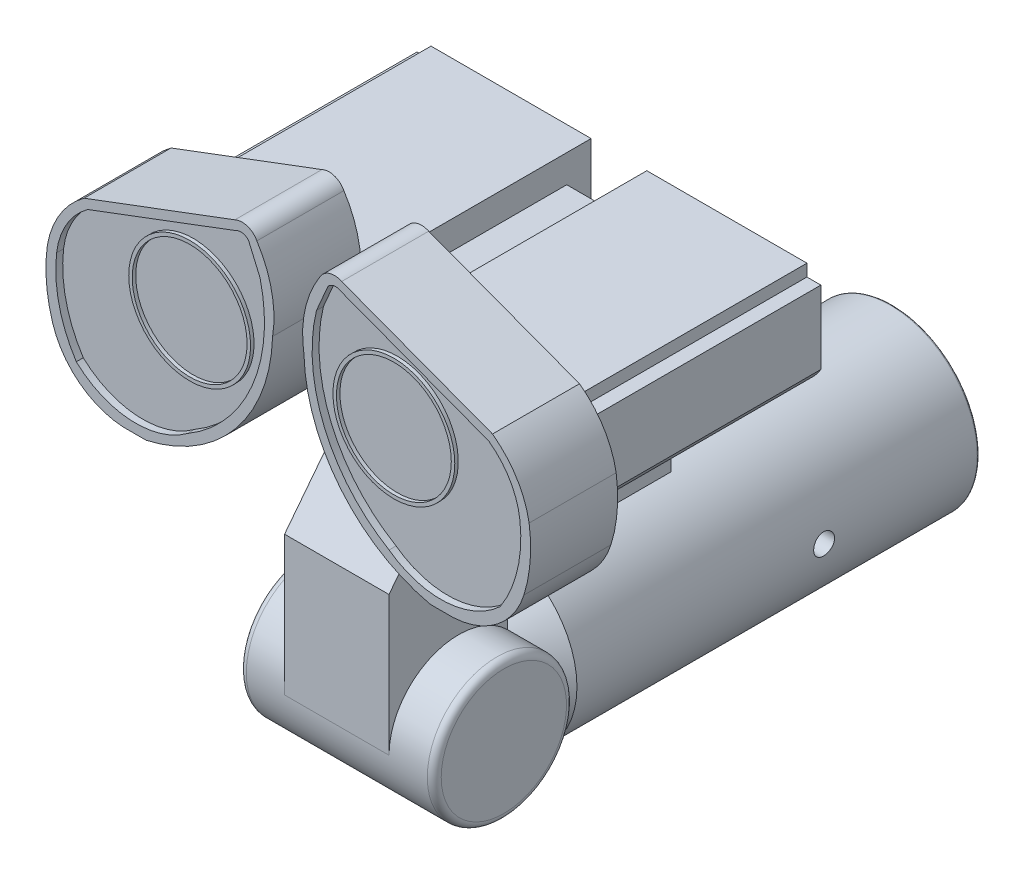
from build123d import *

# Parameters (mm, degrees)
HINGE_CONNECTED_TO_BOTTOM_TUBE_DEPTH      = 1.4
HINGE_CONNECTED_TO_BOTTOM_TUBE_DEPTH_BACK = 1.4
SKETCH3_R                                 = 1
FILLET_ON_HINGE_R                         = 0.1
BASE_CONNECTED_TO_EYES_DEPTH              = 0.75
BASE_CONNECTED_TO_EYES_DEPTH_BACK         = 0.75
EYE_BACKING_DEPTH                         = 3.5
SKETCH7_W                                 = 0.8
SKETCH7_H                                 = 3.5
EYE_BACKING_DETAILS_DEPTH                 = 1.07
SKETCH8_W                                 = 0.8
SKETCH8_H                                 = 1.9
MIDDLE_OF_EYE_BACKING_DEPTH               = 0.67
SKETCH12_R                                = 0.875
OUTER_EYE_DEPTH                           = 1.25
INNER_EYE_CUT_DEPTH                       = 0.1
SKETCH12_5_R                              = 0.875
SKETCH12_5_R_2                            = 0.825
OUTER_LENS_DEPTH                          = 1.2
SKETCH12_7_R                              = 0.825
INNER_LENS_CUT_DEPTH                      = 1.15
CUT_EXTRUDE3_REACH                        = 13.236
SKETCH15_R                                = 0.15
CUT_EXTRUDE3_DIRECTION_2_REACH            = 13.236


with BuildPart() as part:
    # Sketch2 → Bottom tube (revolve)
    with BuildSketch(Plane(origin=(0, 0, 0), x_dir=(0, 0, -1), z_dir=(1, 0, 0))):
        with BuildLine():
            Line((-6.25, 0), (0.163609492, 0))
            add(Edge.make_bspline(
                [(0.163609492, 0), (0.163609492, 1.25), (0, 1.25)],
                knots=[4.71238898, 4.71238898, 4.71238898, 6.283185307, 6.283185307, 6.283185307], degree=2, weights=[1, 0.707106781, 1]))
            Line((0, 1.25), (-5.75, 1.25))
            Line((-5.75, 1.25), (-6.25, 0.75))
            Line((-6.25, 0.75), (-6.25, 0))
        make_face()
    revolve(axis=Axis((0, 0, 6.25), (0, 0, -1)))

    # Sketch3 → Hinge connected to bottom tube (add, two sides: drawn at the far end of the back side and taken through both)
    with BuildSketch(Plane(origin=(0, 0, 0), x_dir=(0, 0, -1), z_dir=(1, 0, 0)).offset(-HINGE_CONNECTED_TO_BOTTOM_TUBE_DEPTH_BACK)):
        with Locations((-6.95, 0)):
            Circle(SKETCH3_R)
    extrude(amount=HINGE_CONNECTED_TO_BOTTOM_TUBE_DEPTH + HINGE_CONNECTED_TO_BOTTOM_TUBE_DEPTH_BACK)

    # fillet on hinge
    fillet_on_hinge_edges = [part.edges().sort_by_distance(p)[0] for p in [
        (1.4, 0, 7.95),
        (-1.4, 0, 7.95),
    ]]
    fillet(fillet_on_hinge_edges, radius=FILLET_ON_HINGE_R)

    # Sketch4 → base connected to eyes (add, two sides: drawn at the far end of the back side and taken through both)
    with BuildSketch(Plane(origin=(0, 0, 0), x_dir=(0, 0, -1), z_dir=(1, 0, 0)).offset(-BASE_CONNECTED_TO_EYES_DEPTH_BACK)):
        with BuildLine():
            Line((-7.95, 0), (-7.95, 2))
            Line((-7.95, 2), (-6.39677242, 4))
            Line((-6.39677242, 4), (-3.89677242, 4))
            Line((-3.89677242, 4), (-3.89677242, 1.5))
            Line((-3.89677242, 1.5), (-6.25, 1.5))
            Line((-6.25, 1.5), (-6.25, 0.714142843))
            ThreePointArc((-6.25, 0.714142843), (-7.337298335, 0.921954446), (-7.95, 0))
        make_face()
    extrude(amount=BASE_CONNECTED_TO_EYES_DEPTH + BASE_CONNECTED_TO_EYES_DEPTH_BACK)

    # Sketch5 → Eye backing (add)
    with BuildSketch(Plane(origin=(0, 0, 3.89677242), x_dir=(-1, 0, 0), z_dir=(0, 0, -1))):
        with BuildLine():
            Line((0.75, 3.5), (2.25, 3.5))
            ThreePointArc((2.25, 3.5), (2.62408667, 3.581702047), (2.9, 3.847197614))
            Line((2.9, 3.847197614), (2.9, 4.897197614))
            Line((2.9, 4.897197614), (2.7, 4.897197614))
            Line((2.7, 4.897197614), (2.7, 5.07))
            Line((2.7, 5.07), (-2.7, 5.07))
            Line((-2.7, 5.07), (-2.7, 4.897197614))
            Line((-2.7, 4.897197614), (-2.9, 4.897197614))
            Line((-2.9, 4.897197614), (-2.9, 3.847197614))
            ThreePointArc((-2.9, 3.847197614), (-2.62408667, 3.581702047), (-2.25, 3.5))
            Line((-2.25, 3.5), (-0.75, 3.5))
            Line((-0.75, 3.5), (-0.75, 4))
            Line((-0.75, 4), (0.75, 4))
            Line((0.75, 4), (0.75, 3.5))
        make_face()
    extrude(amount=-EYE_BACKING_DEPTH)

    # Sketch7 → Eye backing details (cut)
    with BuildSketch(Plane(origin=(0, 5.07, 0), x_dir=(1, 0, 0), z_dir=(0, 1, 0))):
        with Locations((0, -5.64677242)):
            Rectangle(SKETCH7_W, SKETCH7_H)
    extrude(amount=-EYE_BACKING_DETAILS_DEPTH, mode=Mode.SUBTRACT)

    # Sketch8 → Middle of eye backing (add)
    with BuildSketch(Plane(origin=(0, 4, 0), x_dir=(1, 0, 0), z_dir=(0, 1, 0))):
        with Locations((0, -5.19677242)):
            Rectangle(SKETCH8_W, SKETCH8_H)
    extrude(amount=MIDDLE_OF_EYE_BACKING_DEPTH)

    # Sketch12 → Outer eye (add)
    # profile 1 of 2: a face of its own
    with BuildSketch(Plane.XY.offset(7.39677242)):
        with BuildLine():
            ThreePointArc((-0.450961505, 6.145644801), (-0.587867618, 6.261837628), (-0.767083386, 6.250623109))
            Line((-0.767083386, 6.250623109), (-2.933329516, 5.436310045))
            ThreePointArc((-2.933329516, 5.436310045), (-3.278345677, 5.065387345), (-3.459739663, 4.592401064))
            ThreePointArc((-3.459739663, 4.592401064), (-3.474536987, 4.120986543), (-3.384350783, 3.658042637))
            ThreePointArc((-3.384350783, 3.658042637), (-3.001009551, 3.106292928), (-2.371698574, 2.871035758))
            Line((-2.371698574, 2.871035758), (-2.041485898, 2.871035758))
            ThreePointArc((-2.041485898, 2.871035758), (-0.756304939, 3.659066468), (-0.225316176, 5.07))
            ThreePointArc((-0.225316176, 5.07), (-0.238383659, 5.628748724), (-0.450961505, 6.145644801))
        make_face()
        with Locations((-1.466642551, 4.746410471)):
            Circle(SKETCH12_R, mode=Mode.SUBTRACT)
    # profile 2 of 2: a face of its own
    with BuildSketch(Plane.XY.offset(7.39677242)):
        with BuildLine():
            Line((2.041485898, 2.871035758), (2.371698574, 2.871035758))
            ThreePointArc((2.371698574, 2.871035758), (3.001009551, 3.106292928), (3.384350783, 3.658042637))
            ThreePointArc((3.384350783, 3.658042637), (3.474536987, 4.120986543), (3.459739663, 4.592401064))
            ThreePointArc((3.459739663, 4.592401064), (3.278345677, 5.065387345), (2.933329516, 5.436310045))
            Line((2.933329516, 5.436310045), (0.767083386, 6.250623109))
            ThreePointArc((0.767083386, 6.250623109), (0.587867618, 6.261837628), (0.450961505, 6.145644801))
            ThreePointArc((0.450961505, 6.145644801), (0.238383659, 5.628748724), (0.225316176, 5.07))
            ThreePointArc((0.225316176, 5.07), (0.756304939, 3.659066468), (2.041485898, 2.871035758))
        make_face()
        with Locations((1.466642551, 4.746410471)):
            Circle(SKETCH12_R, mode=Mode.SUBTRACT)
    extrude(amount=OUTER_EYE_DEPTH)

    # Sketch13 → Inner eye cut (cut)
    with BuildSketch(Plane.XY.offset(8.64677242)):
        with BuildLine():
            Line((-0.757964351, 6.121312443), (-2.880162803, 5.322245904))
            ThreePointArc((-2.880162803, 5.322245904), (-3.184019481, 4.988025414), (-3.327634423, 4.55976502))
            ThreePointArc((-3.327634423, 4.55976502), (-3.29208127, 3.928007422), (-3.044809473, 3.345565711))
            ThreePointArc((-3.044809473, 3.345565711), (-2.263619647, 3.009419304), (-1.448470515, 3.251873102))
            ThreePointArc((-1.448470515, 3.251873102), (-0.52016025, 4.307569927), (-0.404930121, 5.708633007))
            Line((-0.404930121, 5.708633007), (-0.570058708, 6.091643131))
            ThreePointArc((-0.570058708, 6.091643131), (-0.658423401, 6.141869268), (-0.757964351, 6.121312443))
        make_face()
        with BuildLine():
            Line((0.570058708, 6.091643131), (0.404930121, 5.708633007))
            ThreePointArc((0.404930121, 5.708633007), (0.52016025, 4.307569927), (1.448470515, 3.251873102))
            ThreePointArc((1.448470515, 3.251873102), (2.263619647, 3.009419304), (3.044809473, 3.345565711))
            ThreePointArc((3.044809473, 3.345565711), (3.29208127, 3.928007422), (3.327634423, 4.55976502))
            ThreePointArc((3.327634423, 4.55976502), (3.184019481, 4.988025414), (2.880162803, 5.322245904))
            Line((2.880162803, 5.322245904), (0.757964351, 6.121312443))
            ThreePointArc((0.757964351, 6.121312443), (0.658423401, 6.141869268), (0.570058708, 6.091643131))
        make_face()
    extrude(amount=-INNER_EYE_CUT_DEPTH, mode=Mode.SUBTRACT)

    # Sketch12_5 → Outer lens (add)
    # profile 1 of 2: a face of its own
    with BuildSketch(Plane.XY.offset(7.39677242)):
        with Locations((-1.466642551, 4.746410471)):
            Circle(SKETCH12_5_R)
        with Locations((-1.466642551, 4.746410471)):
            Circle(SKETCH12_5_R_2, mode=Mode.SUBTRACT)
    # profile 2 of 2: a face of its own
    with BuildSketch(Plane.XY.offset(7.39677242)):
        with Locations((1.466642551, 4.746410471)):
            Circle(SKETCH12_5_R)
        with Locations((1.466642551, 4.746410471)):
            Circle(SKETCH12_5_R_2, mode=Mode.SUBTRACT)
    extrude(amount=OUTER_LENS_DEPTH)

    # Sketch12_7 → Inner lens cut (add)
    with BuildSketch(Plane.XY.offset(7.39677242)):
        with Locations((-1.466642551, 4.746410471)):
            Circle(SKETCH12_7_R)
        with Locations((1.466642551, 4.746410471)):
            Circle(SKETCH12_7_R)
    extrude(amount=INNER_LENS_CUT_DEPTH)

    # Sketch15 → Cut-Extrude3 (cut, up to next)
    with BuildSketch(Plane(origin=(0, 0, 0), x_dir=(0, 0, -1), z_dir=(1, 0, 0)), mode=Mode.PRIVATE) as cut_extrude3_sk1:
        with Locations((-2.2, 0)):
            Circle(SKETCH15_R)
    cut_extrude3_tool1 = extrude(cut_extrude3_sk1.sketch, amount=-CUT_EXTRUDE3_REACH, mode=Mode.PRIVATE) & part.part
    add(cut_extrude3_tool1.solids().sort_by_distance((0, 0, 2.2))[0], mode=Mode.SUBTRACT)

    # Sketch15 → Cut-Extrude3 direction 2 (cut, up to next)
    with BuildSketch(Plane(origin=(0, 0, 0), x_dir=(0, 0, -1), z_dir=(1, 0, 0)), mode=Mode.PRIVATE) as cut_extrude3_direction_2_sk1:
        with Locations((-2.2, 0)):
            Circle(SKETCH15_R)
    cut_extrude3_direction_2_tool1 = extrude(cut_extrude3_direction_2_sk1.sketch, amount=CUT_EXTRUDE3_DIRECTION_2_REACH, mode=Mode.PRIVATE) & part.part
    add(cut_extrude3_direction_2_tool1.solids().sort_by_distance((0, 0, 2.2))[0], mode=Mode.SUBTRACT)


solid = part.part
